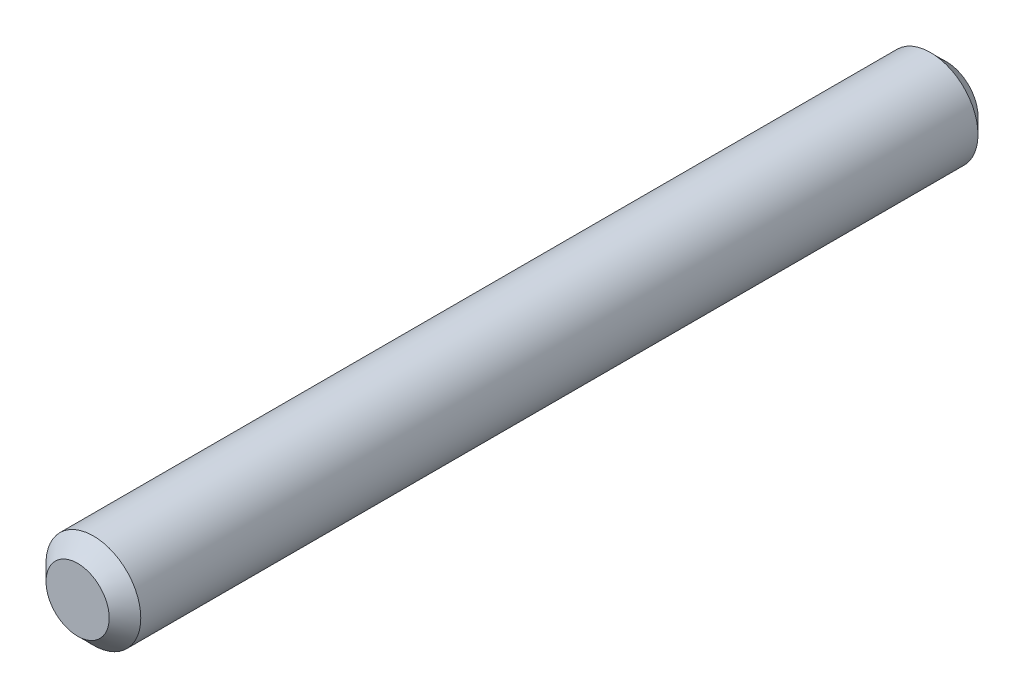
from build123d import *

# Parameters (mm, degrees)
SKETCH1_R           = 3
BOSS_EXTRUDE1_DEPTH = 55
CHAMFER1_SIZE       = 1


with BuildPart() as part:
    # Sketch1 → Boss-Extrude1 (new body)
    with BuildSketch(Plane.XY):
        Circle(SKETCH1_R)
    extrude(amount=BOSS_EXTRUDE1_DEPTH)

    # Chamfer1
    chamfer1_edges = [part.edges().sort_by_distance(p)[0] for p in [
        (-3, 0, 0),
        (-3, 0, 55),
    ]]
    chamfer(chamfer1_edges, length=CHAMFER1_SIZE)


solid = part.part
